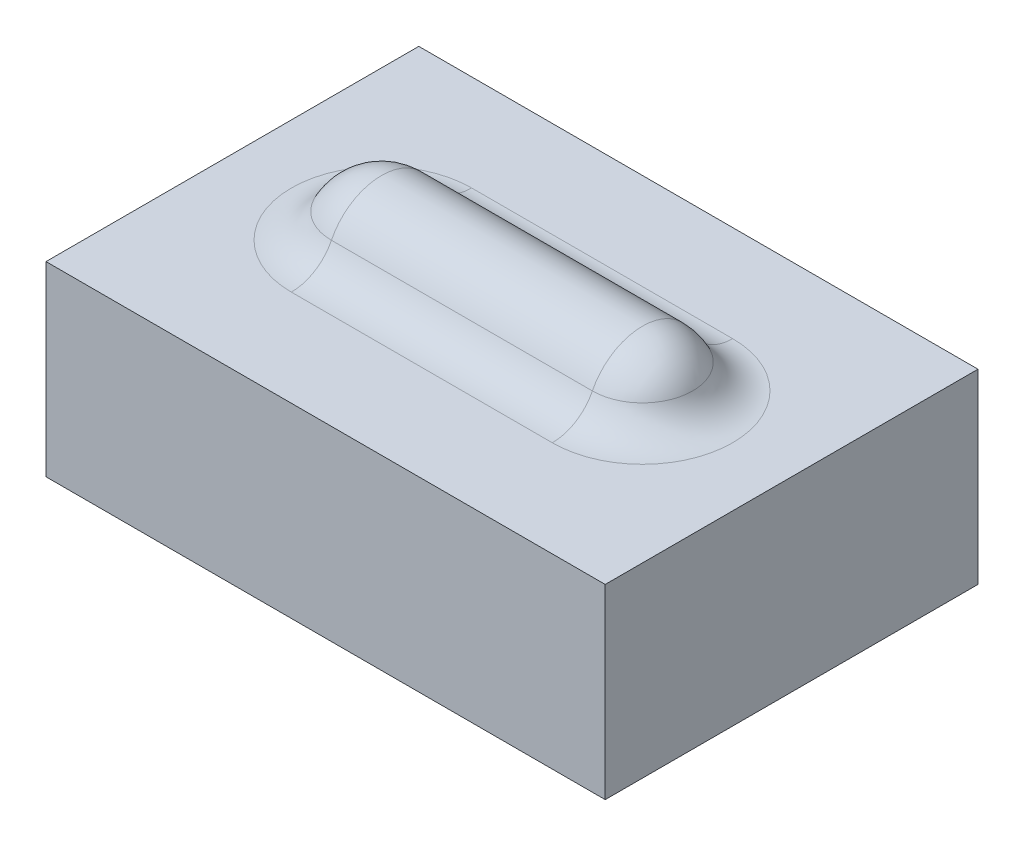
from build123d import *

# Parameters (mm, degrees)
SKETCH_1_W      = 15
SKETCH_1_H      = 10
EXTRUDE_1_DEPTH = 5
FILLET_1_R      = 1.2


with BuildPart() as part:
    # 草图1 → 凸台-拉伸1 (new body)
    with BuildSketch(Plane(origin=(0, 0, 0), x_dir=(1, 0, 0), z_dir=(0, 1, 0))):
        Rectangle(SKETCH_1_W, SKETCH_1_H)
    extrude(amount=EXTRUDE_1_DEPTH)

    # 草图2 → 旋转1 (revolve)
    with BuildSketch(Plane.XY):
        with BuildLine():
            Line((-3.5, 6.5), (3.5, 6.5))
            ThreePointArc((3.5, 6.5), (4.560660172, 6.060660172), (5, 5))
            Line((5, 5), (-5, 5))
            ThreePointArc((-5, 5), (-4.560660172, 6.060660172), (-3.5, 6.5))
        make_face()
    revolve(axis=Axis((-7.5, 5, 0), (1, 0, 0)))

    # 圆角1
    fillet_1_edges = [part.edges().sort_by_distance(p)[0] for p in [
        (0, 5, 1.5),
        (4.560660172, 5, -1.060660172),
        (-4.560660172, 5, 1.060660172),
        (0, 5, -1.5),
    ]]
    fillet(fillet_1_edges, radius=FILLET_1_R)


solid = part.part
